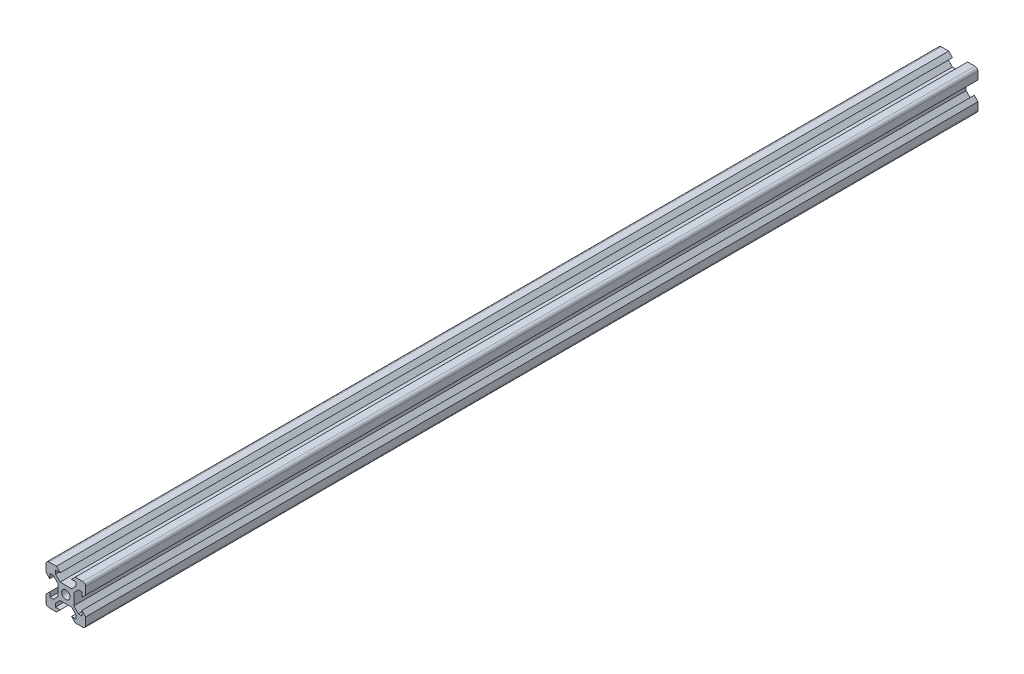
from build123d import *

# Parameters (mm, degrees)
SKETCH1_R           = 2.125
BOSS_EXTRUDE1_DEPTH = 450


with BuildPart() as part:
    # Sketch1 → Boss-Extrude1 (new body)
    with BuildSketch(Plane.XY):
        with BuildLine():
            Line((8.1, 5.225), (8.1, 2.85))
            Line((8.1, 2.85), (10, 4.75))
            Line((10, 4.75), (10, 8.5))
            ThreePointArc((10, 8.5), (9.560660172, 9.560660172), (8.5, 10))
            Line((8.5, 10), (4.75, 10))
            Line((4.75, 10), (2.85, 8.1))
            Line((2.85, 8.1), (5.225, 8.1))
            Line((5.225, 8.1), (5.225, 6.325))
            Line((5.225, 6.325), (2.9, 4))
            Line((2.9, 4), (-2.9, 4))
            Line((-2.9, 4), (-5.225, 6.325))
            Line((-5.225, 6.325), (-5.225, 8.1))
            Line((-5.225, 8.1), (-2.85, 8.1))
            Line((-2.85, 8.1), (-4.75, 10))
            Line((-4.75, 10), (-8.5, 10))
            ThreePointArc((-8.5, 10), (-9.560660172, 9.560660172), (-10, 8.5))
            Line((-10, 8.5), (-10, 4.75))
            Line((-10, 4.75), (-8.1, 2.85))
            Line((-8.1, 2.85), (-8.1, 5.225))
            Line((-8.1, 5.225), (-6.325, 5.225))
            Line((-6.325, 5.225), (-4, 2.9))
            Line((-4, 2.9), (-4, -2.9))
            Line((-4, -2.9), (-6.325, -5.225))
            Line((-6.325, -5.225), (-8.1, -5.225))
            Line((-8.1, -5.225), (-8.1, -2.85))
            Line((-8.1, -2.85), (-10, -4.75))
            Line((-10, -4.75), (-10, -8.5))
            ThreePointArc((-10, -8.5), (-9.560660172, -9.560660172), (-8.5, -10))
            Line((-8.5, -10), (-4.75, -10))
            Line((-4.75, -10), (-2.85, -8.1))
            Line((-2.85, -8.1), (-5.225, -8.1))
            Line((-5.225, -8.1), (-5.225, -6.325))
            Line((-5.225, -6.325), (-2.9, -4))
            Line((-2.9, -4), (2.9, -4))
            Line((2.9, -4), (5.225, -6.325))
            Line((5.225, -6.325), (5.225, -8.1))
            Line((5.225, -8.1), (2.85, -8.1))
            Line((2.85, -8.1), (4.75, -10))
            Line((4.75, -10), (8.5, -10))
            ThreePointArc((8.5, -10), (9.560660172, -9.560660172), (10, -8.5))
            Line((10, -8.5), (10, -4.75))
            Line((10, -4.75), (8.1, -2.85))
            Line((8.1, -2.85), (8.1, -5.225))
            Line((8.1, -5.225), (6.325, -5.225))
            Line((6.325, -5.225), (4, -2.9))
            Line((4, -2.9), (4, 2.9))
            Line((4, 2.9), (6.325, 5.225))
            Line((6.325, 5.225), (8.1, 5.225))
        make_face()
        Circle(SKETCH1_R, mode=Mode.SUBTRACT)
    extrude(amount=BOSS_EXTRUDE1_DEPTH)


solid = part.part
